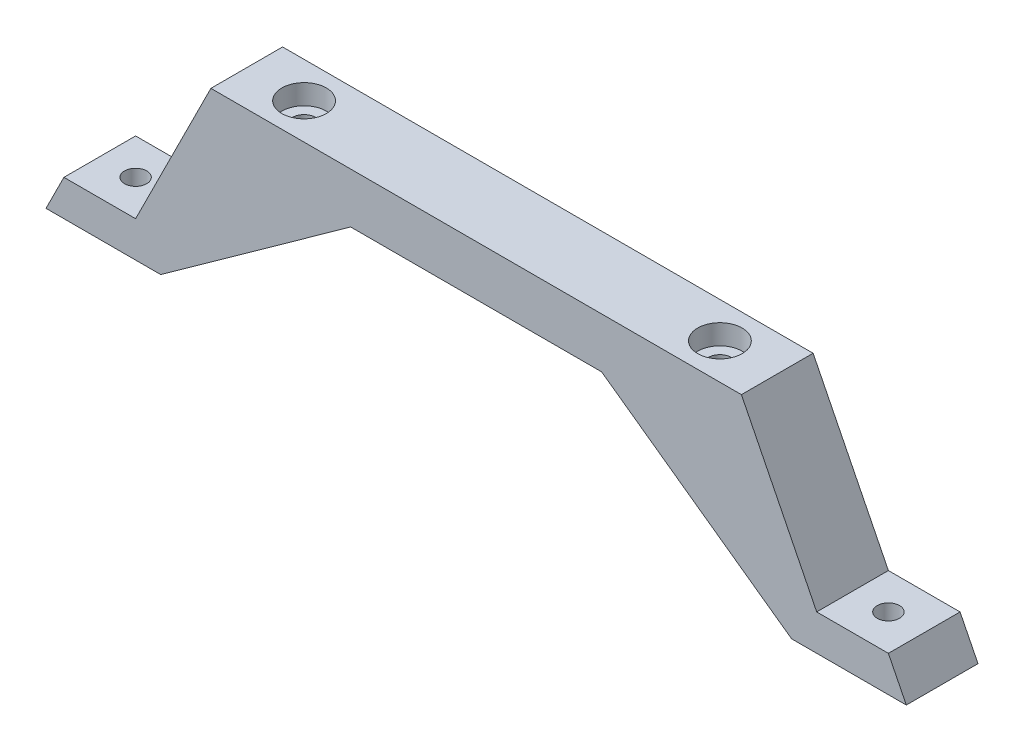
from build123d import *

# Parameters (mm, degrees)
EXTRUDE_1_DEPTH     = 10
SKETCH_2_R          = 1.6
CUT_EXTRUDE_2_DEPTH = 27
SKETCH_3_R          = 3.1
CUT_EXTRUDE_3_DEPTH = 2.8
SKETCH_5_R          = 1.55
CUT_EXTRUDE_4_DEPTH = 6


with BuildPart() as part:
    # 草图1 → 凸台-拉伸1 (new body)
    with BuildSketch(Plane.XY):
        Polygon((-3.188712924, 13.052848472), (33.811287076, 13.052848472), (33.811287076, 6.052848472), (16.311287076, 6.052848472), (-10.188712924, -12.947151528), (-26.188712924, -12.947151528), (-23.688712924, -7.947151528), (-13.688712924, -7.947151528), align=None)
    extrude_1 = extrude(amount=EXTRUDE_1_DEPTH)

    # 镜向1: 凸台-拉伸1 across plane
    add(extrude_1.mirror(Plane(origin=(33.811287076, 13.052848472, 10), x_dir=(0, 0, 1), z_dir=(-1, 0, 0))))

    # 草图2 → 切除-拉伸2 (cut, through all)
    with BuildSketch(Plane(origin=(0, 13.052848472, 0), x_dir=(1, 0, 0), z_dir=(0, 1, 0))):
        with Locations((4.811287076, -5)):
            Circle(SKETCH_2_R)
        with Locations((62.811287076, -5)):
            Circle(SKETCH_2_R)
    extrude(amount=-CUT_EXTRUDE_2_DEPTH, mode=Mode.SUBTRACT)

    # 草图3 → 切除-拉伸3 (cut)
    with BuildSketch(Plane(origin=(0, 13.052848472, 0), x_dir=(1, 0, 0), z_dir=(0, 1, 0))):
        with Locations((4.811287076, -5)):
            Circle(SKETCH_3_R)
        with Locations((62.811287076, -5)):
            Circle(SKETCH_3_R)
    extrude(amount=-CUT_EXTRUDE_3_DEPTH, mode=Mode.SUBTRACT)

    # 草图5 → 切除-拉伸4 (cut, through all)
    with BuildSketch(Plane(origin=(0, -7.947151528, 0), x_dir=(1, 0, 0), z_dir=(0, 1, 0))):
        with Locations((-18.688712924, -5)):
            Circle(SKETCH_5_R)
        with Locations((86.311287076, -5)):
            Circle(SKETCH_5_R)
    extrude(amount=-CUT_EXTRUDE_4_DEPTH, mode=Mode.SUBTRACT)


solid = part.part
